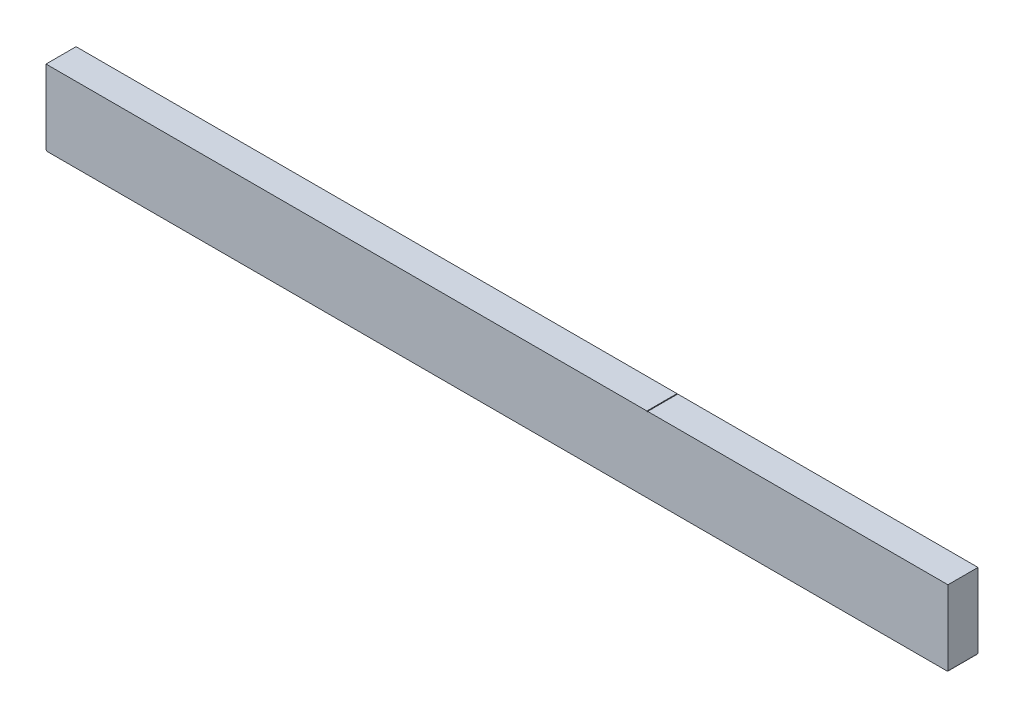
from build123d import *

# Parameters (mm, degrees)
SKETCH1_W           = 200
SKETCH1_H           = 500
BOSS_EXTRUDE1_DEPTH = 6000
SKETCH3_W           = 5
SKETCH3_H           = 10
CUT_EXTRUDE1_DEPTH  = 201


with BuildPart() as part:
    # Sketch1 → Boss-Extrude1 (new body)
    with BuildSketch(Plane(origin=(0, 0, 0), x_dir=(0, 0, -1), z_dir=(1, 0, 0))):
        Rectangle(SKETCH1_W, SKETCH1_H)
    extrude(amount=BOSS_EXTRUDE1_DEPTH)

    # Sketch3 → Cut-Extrude1 (cut, through all)
    with BuildSketch(Plane.XY.offset(100)):
        with Locations((0, -250)):
            Rectangle(SKETCH3_W, SKETCH3_H)
        with Locations((6000, -250)):
            Rectangle(SKETCH3_W, SKETCH3_H)
        with Locations((4000, 250)):
            Rectangle(SKETCH3_W, SKETCH3_H)
    extrude(amount=-CUT_EXTRUDE1_DEPTH, mode=Mode.SUBTRACT)


solid = part.part
